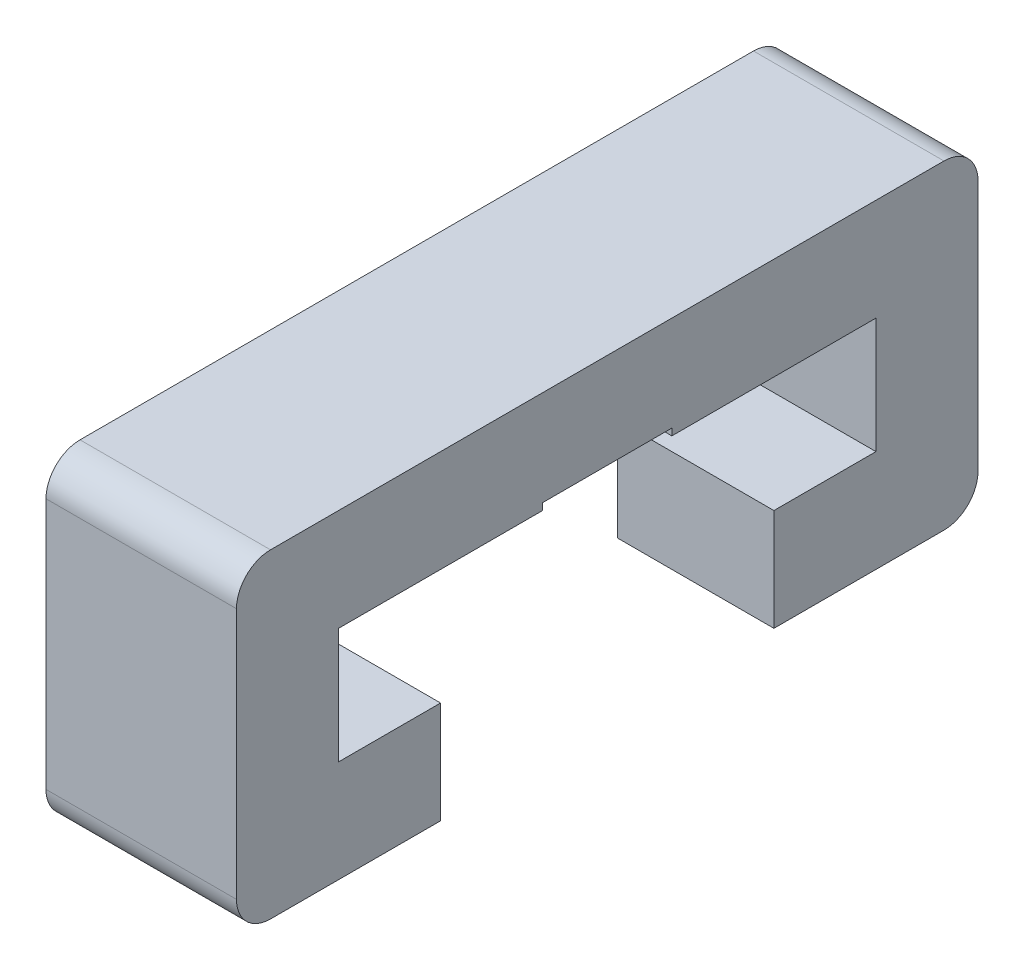
from build123d import *

# Parameters (mm, degrees)
BOSS_EXTRUDE_CLIP_DEPTH       = 2.8
BOSS_EXTRUDE_START            = -2.8
CLIP_OUTLINE_3_W              = 1.9
CLIP_OUTLINE_3_H              = 0.1
BOSS_EXTRUDE_CLIP_NOTCH_DEPTH = 1.240192379
CHAMFER_CLIP_SIZE             = 0.5


with BuildPart() as part:
    # Clip outline → Boss-Extrude clip (new body)
    with BuildSketch(Plane(origin=(0, 0, 0), x_dir=(0, 0, -1), z_dir=(1, 0, 0))):
        with BuildLine():
            Line((-4.95, 2.2), (-2.45, 2.2))
            Line((-2.45, 2.2), (-2.45, 3.7))
            Line((-2.45, 3.7), (-3.95, 3.7))
            Line((-3.95, 3.7), (-3.95, 5.4))
            Line((-3.95, 5.4), (-0.95, 5.4))
            Line((-0.95, 5.4), (-0.95, 5.5))
            Line((-0.95, 5.5), (0.95, 5.5))
            Line((0.95, 5.5), (0.95, 5.4))
            Line((0.95, 5.4), (3.95, 5.4))
            Line((3.95, 5.4), (3.95, 3.7))
            Line((3.95, 3.7), (2.45, 3.7))
            Line((2.45, 3.7), (2.45, 2.2))
            Line((2.45, 2.2), (4.95, 2.2))
            ThreePointArc((4.95, 2.2), (5.303553391, 2.346446609), (5.45, 2.7))
            Line((5.45, 2.7), (5.45, 6.4))
            ThreePointArc((5.45, 6.4), (5.303553391, 6.753553391), (4.95, 6.9))
            Line((4.95, 6.9), (-4.95, 6.9))
            ThreePointArc((-4.95, 6.9), (-5.303553391, 6.753553391), (-5.45, 6.4))
            Line((-5.45, 6.4), (-5.45, 2.7))
            ThreePointArc((-5.45, 2.7), (-5.303553391, 2.346446609), (-4.95, 2.2))
        make_face()
    extrude(amount=-BOSS_EXTRUDE_CLIP_DEPTH)

    # Clip outline_3 → Boss-Extrude clip notch (add)
    with BuildSketch(Plane(origin=(0, 0, 0), x_dir=(0, 0, -1), z_dir=(1, 0, 0)).offset(BOSS_EXTRUDE_START)):
        with Locations((0, 5.45)):
            Rectangle(CLIP_OUTLINE_3_W, CLIP_OUTLINE_3_H)
    extrude(amount=BOSS_EXTRUDE_CLIP_NOTCH_DEPTH)

    # Chamfer clip
    chamfer_clip_edges = [part.edges().sort_by_distance(p)[0] for p in [
        (-2.8, 2.95, 2.45),
        (-2.8, 3.7, 3.2),
        (-2.8, 4.55, 3.95),
        (-2.8, 5.4, 0),
        (-2.8, 4.55, -3.95),
        (-2.8, 3.7, -3.2),
        (-2.8, 2.95, -2.45),
    ]]
    chamfer(chamfer_clip_edges, length=CHAMFER_CLIP_SIZE)


solid = part.part
